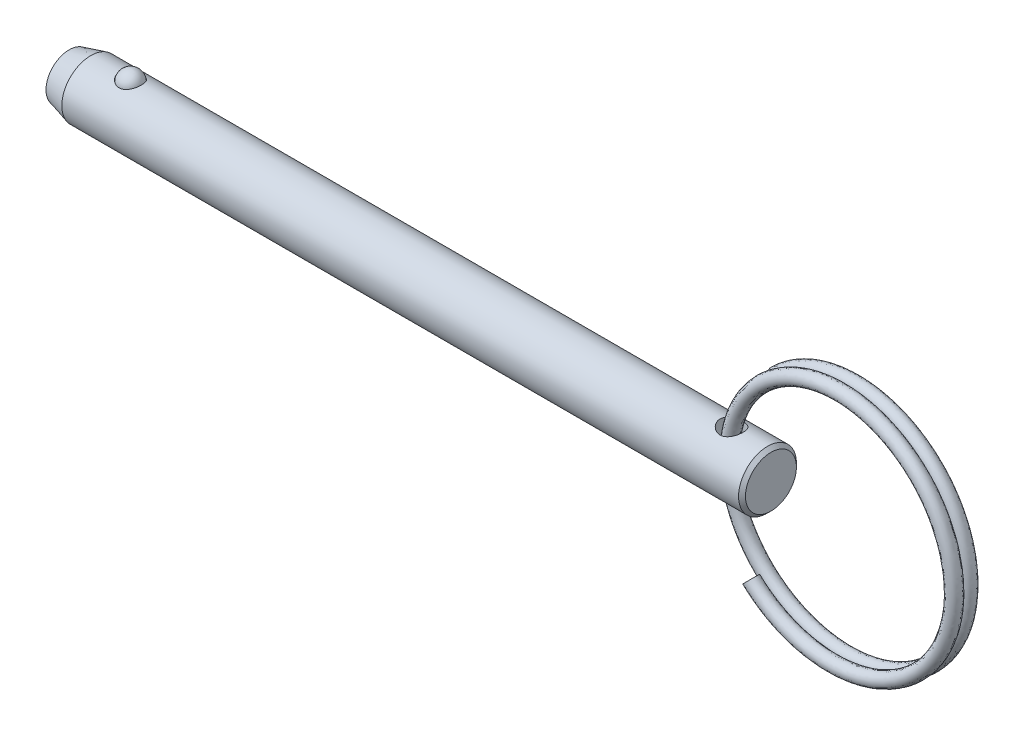
from build123d import *

# Parameters (mm, degrees)
SKETCH4_W          = 1.27
SKETCH4_H          = 6.35
SWEEP1_PITCH       = 1.5494
SWEEP1_HEIGHT      = 1.355725
SWEEP1_RADIUS      = 13.462
SKETCH6_R          = 0.762
SWEEP2_PITCH       = 1.5494
SWEEP2_HEIGHT      = 1.355725
SWEEP2_RADIUS      = 13.462
SWEEP2_START_ANGLE = -180
SKETCH6_2_R        = 0.762


with BuildPart() as part:
    # Sketch1 → Revolve1 (revolve)
    with BuildSketch(Plane.XY):
        Polygon((38.5064, 2.794), (38.1254, 3.175), (-36.136547737, 3.175), (-38.5064, 2.54), (-38.5064, 0), (38.5064, 0), align=None)
    revolve(axis=Axis((38.5064, 0, 0), (1, 0, 0)))

    # Sketch2 → Cut-Revolve1 (revolve, cut)
    with BuildSketch(Plane.XY):
        with BuildLine():
            Line((-30.514582051, 2.8575), (-33.029182051, 2.8575))
            ThreePointArc((-33.029182051, 2.8575), (-31.771882051, 4.1148), (-30.514582051, 2.8575))
        make_face()
    revolve(axis=Axis((-30.514582051, 2.8575, 0), (1, 0, 0)), mode=Mode.SUBTRACT)

    # Sketch4 → Cut-Revolve2 (revolve, cut)
    with BuildSketch(Plane.XY):
        with Locations((34.8234, 0)):
            Rectangle(SKETCH4_W, SKETCH4_H)
    revolve(axis=Axis((34.1884, -3.175, 0), (0, 1, 0)), mode=Mode.SUBTRACT)


with BuildPart() as body_2:
    # Sketch3 → Revolve2 (revolve)
    with BuildSketch(Plane.XY):
        with BuildLine():
            Line((-30.539982051, 2.8575), (-33.003782051, 2.8575))
            ThreePointArc((-33.003782051, 2.8575), (-31.771882051, 4.0894), (-30.539982051, 2.8575))
        make_face()
    revolve(axis=Axis((-30.539982051, 2.8575, 0), (1, 0, 0)))


with BuildPart() as body_3:
    # Sweep1: sweep along a helix
    with BuildLine() as sweep1_path:
        Helix(SWEEP1_PITCH, SWEEP1_HEIGHT, SWEEP1_RADIUS, center=(46.673425091, 0, 0), direction=(0, 0, -1), lefthand=True)
    # Sketch6 → Sweep1 (sweep)
    with BuildSketch(Plane(origin=(114.003847968, 0, 0), x_dir=(0, 0, -1), z_dir=(0, 1, 0))):
        with Locations((0, 80.030422877)):
            Circle(SKETCH6_R)
    sweep(path=sweep1_path.line, is_frenet=True)

    # Sweep2: sweep along a helix
    with BuildLine() as sweep2_path:
        add(Helix(SWEEP2_PITCH, SWEEP2_HEIGHT, SWEEP2_RADIUS, center=(46.673425091, 0, 0), direction=(0, 0, 1), lefthand=True, mode=Mode.PRIVATE).rotate(Axis((46.673425091, 0, 0), (0, 0, 1)), SWEEP2_START_ANGLE))
    # Sketch6_2 → Sweep2 (sweep)
    with BuildSketch(Plane(origin=(114.003847968, 0, 0), x_dir=(0, 0, -1), z_dir=(0, 1, 0))):
        with Locations((0, 80.030422877)):
            Circle(SKETCH6_2_R)
    sweep(path=sweep2_path.line, is_frenet=True)


solid = Compound([part.part, body_2.part, body_3.part])
